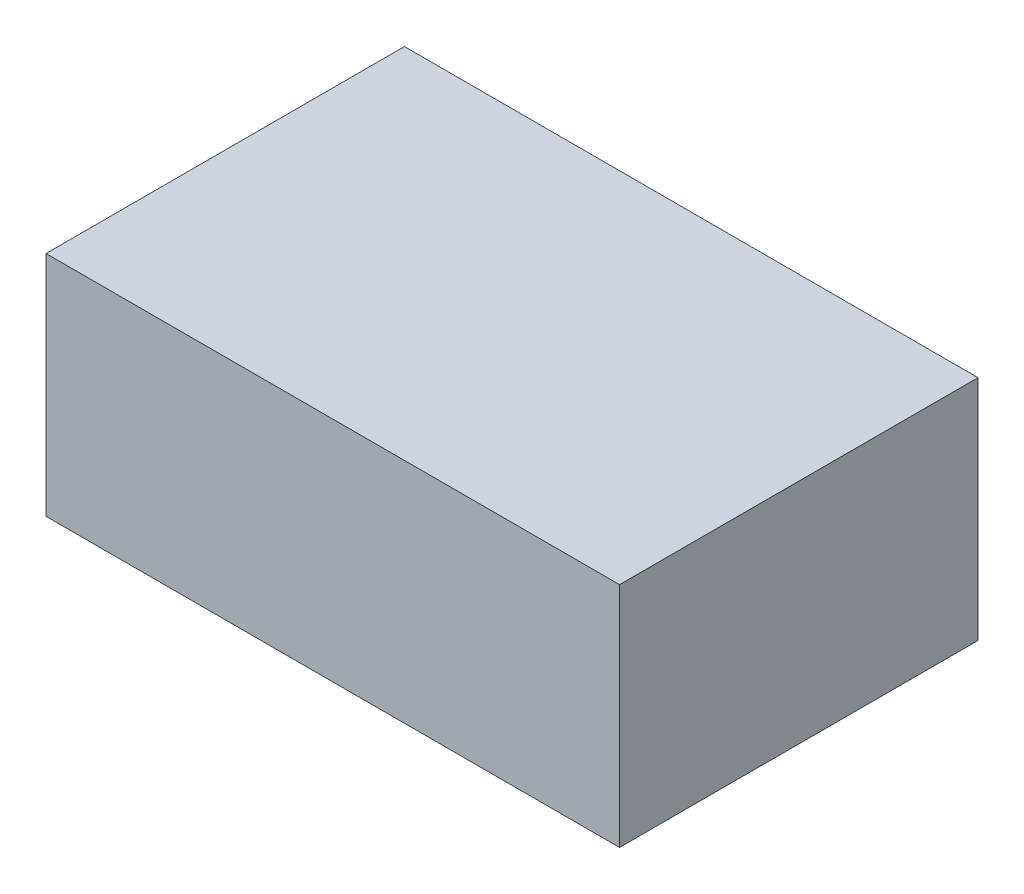
from build123d import *

# Parameters (mm, degrees)
SKETCH1_W           = 8
SKETCH1_H           = 5
BOSS_EXTRUDE1_DEPTH = 3.175


with BuildPart() as part:
    # Sketch1 → Boss-Extrude1 (new body)
    with BuildSketch(Plane(origin=(0, 0, 0), x_dir=(1, 0, 0), z_dir=(0, 1, 0))):
        Rectangle(SKETCH1_W, SKETCH1_H)
    extrude(amount=BOSS_EXTRUDE1_DEPTH)


solid = part.part
